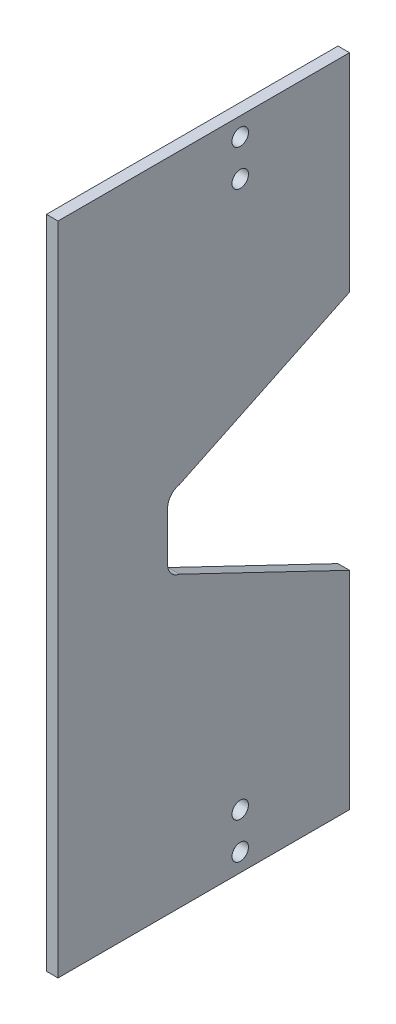
from build123d import *

# Parameters (mm, degrees)
SKETCH_1_R          = 1.1303
EXTRUDE_1_DEPTH     = 1.588
FILLET_1_R          = 2
FILLET_2_R          = 2
FILLET_3_R          = 2
FILLET_4_R          = 2
SKETCH_2_W          = 12
SKETCH_2_H          = 89.95
EXTRUDE_2_DEPTH     = 1.588
CUT_EXTRUDE_1_DEPTH = 10


with BuildPart() as part:
    # 草图1 → 凸台-拉伸1 (new body)
    with BuildSketch(Plane(origin=(-0.79375, 0, 0), x_dir=(0, -1, 0), z_dir=(-1, 0, 0))):
        with BuildLine():
            Line((38.795, 5), (12.795, 5))
            ThreePointArc((12.795, 5), (11.380786438, 4.414213562), (10.795, 3))
            Line((10.795, 3), (10.795, -13))
            ThreePointArc((10.795, -13), (11.380786438, -14.414213562), (12.795, -15))
            Line((12.795, -15), (47.795, -15))
            Line((47.795, -15), (50.77, -0.039144756))
            Line((50.77, -0.039144756), (55.77, -0.039144756))
            Line((55.77, -0.039144756), (60.77, -0.039144756))
            Line((60.77, -0.039144756), (63.745, -15))
            Line((63.745, -15), (98.745, -15))
            ThreePointArc((98.745, -15), (100.159213562, -14.414213562), (100.745, -13))
            Line((100.745, -13), (100.745, 3))
            ThreePointArc((100.745, 3), (100.159213562, 4.414213562), (98.745, 5))
            Line((98.745, 5), (72.745, 5))
            Line((72.745, 5), (38.795, 5))
        make_face()
        with Locations((13.295, -10)):
            Circle(SKETCH_1_R, mode=Mode.SUBTRACT)
        with Locations((18.295, -10)):
            Circle(SKETCH_1_R, mode=Mode.SUBTRACT)
        with Locations((93.245, -10)):
            Circle(SKETCH_1_R, mode=Mode.SUBTRACT)
        with Locations((98.245, -10)):
            Circle(SKETCH_1_R, mode=Mode.SUBTRACT)
    extrude(amount=-EXTRUDE_1_DEPTH)

    # 圆角1
    fillet_1_edges = [part.edges().sort_by_distance(p)[0] for p in [
        (0.00025, -47.795, -15),
    ]]
    fillet(fillet_1_edges, radius=FILLET_1_R)

    # 圆角2
    fillet_2_edges = [part.edges().sort_by_distance(p)[0] for p in [
        (0.00025, -50.77, -0.039144756),
    ]]
    fillet(fillet_2_edges, radius=FILLET_2_R)

    # 圆角3
    fillet_3_edges = [part.edges().sort_by_distance(p)[0] for p in [
        (0.00025, -60.77, -0.039144756),
    ]]
    fillet(fillet_3_edges, radius=FILLET_3_R)

    # 圆角4
    fillet_4_edges = [part.edges().sort_by_distance(p)[0] for p in [
        (0.00025, -63.745, -15),
    ]]
    fillet(fillet_4_edges, radius=FILLET_4_R)

    # 草图2 → 凸台-拉伸2 (add)
    with BuildSketch(Plane(origin=(0.79425, 0, 0), x_dir=(0, 0, -1), z_dir=(1, 0, 0))):
        with Locations((-9, -55.77)):
            Rectangle(SKETCH_2_W, SKETCH_2_H)
        Polygon((13.39006724, -48.115138781), (25, -45.806477318), (25, -10.795), (13, -10.795), align=None)
        Polygon((13.39006724, -63.424861219), (25, -65.733522682), (25, -100.745), (13, -100.745), align=None)
    extrude(amount=-EXTRUDE_2_DEPTH)

    # 草图5 → 切除-拉伸1 (cut)
    with BuildSketch(Plane(origin=(0.79425, 0, 0), x_dir=(0, 0, -1), z_dir=(1, 0, 0))):
        Polygon((1.649077515, -50.449861219), (25, -45.806477318), (25, -39.241825321), align=None)
        Polygon((1.649077515, -61.090138781), (25, -72.298174679), (25, -65.733522682), align=None)
    extrude(amount=-CUT_EXTRUDE_1_DEPTH, mode=Mode.SUBTRACT)


solid = part.part
